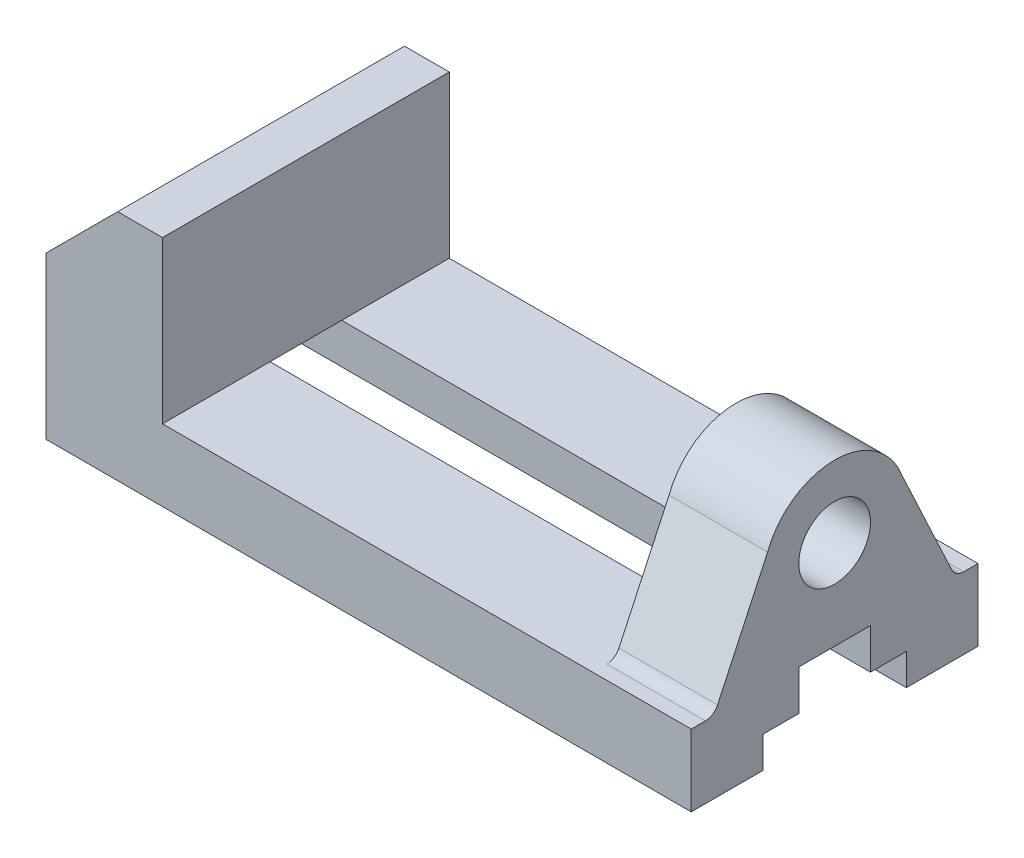
from build123d import *

# Parameters (mm, degrees)
SKETCH1_W                  = 144
SKETCH1_H                  = 64
BOSS_EXTRUDE1_DEPTH        = 16
SKETCH2_W                  = 26
SKETCH2_H                  = 64
BOSS_EXTRUDE2_DEPTH        = 36
CUT_EXTRUDE1_DEPTH         = 1
CUT_EXTRUDE1_DEPTH_BACK    = 65
SKETCH4_W                  = 22
SKETCH4_H                  = 64
BOSS_EXTRUDE3_DEPTH        = 36
CUT_EXTRUDE2_DEPTH         = 1
CUT_EXTRUDE2_DEPTH_BACK    = 145
SKETCH6_R                  = 8
CUT_EXTRUDE3_DEPTH         = 36
F_12_0MM_DOWEL_HOLE1_D     = 12
F_12_0MM_DOWEL_HOLE1_DEPTH = 10
F_12_0MM_DOWEL_HOLE1_TIP   = 3.605163714


with BuildPart() as part:
    # Sketch1 → Boss-Extrude1 (new body)
    with BuildSketch(Plane(origin=(0, 0, 0), x_dir=(1, 0, 0), z_dir=(0, 1, 0))):
        Rectangle(SKETCH1_W, SKETCH1_H)
    extrude(amount=BOSS_EXTRUDE1_DEPTH)

    # Sketch2 → Boss-Extrude2 (add)
    with BuildSketch(Plane(origin=(0, 16, 0), x_dir=(1, 0, 0), z_dir=(0, 1, 0))):
        with Locations((-59, 0)):
            Rectangle(SKETCH2_W, SKETCH2_H)
    extrude(amount=BOSS_EXTRUDE2_DEPTH)

    # Sketch3 → Cut-Extrude1 (cut, two sides)
    with BuildSketch(Plane.XY.offset(32)) as cut_extrude1_sk:
        Polygon((-72, 36), (-56, 52), (-72, 52), align=None)
    extrude(amount=CUT_EXTRUDE1_DEPTH, mode=Mode.SUBTRACT)
    extrude(cut_extrude1_sk.sketch, amount=-CUT_EXTRUDE1_DEPTH_BACK, mode=Mode.SUBTRACT)

    # Sketch4 → Boss-Extrude3 (add)
    with BuildSketch(Plane(origin=(0, 16, 0), x_dir=(1, 0, 0), z_dir=(0, 1, 0))):
        with Locations((61, 0)):
            Rectangle(SKETCH4_W, SKETCH4_H)
    extrude(amount=BOSS_EXTRUDE3_DEPTH)

    # Sketch5 → Cut-Extrude2 (cut, two sides)
    with BuildSketch(Plane(origin=(72, 0, 0), x_dir=(0, 0, -1), z_dir=(1, 0, 0))) as cut_extrude2_sk:
        Polygon((-16, 7), (-16, 0), (16, 0), (16, 7), (8, 7), (8, 16), (-8, 16), (-8, 7), align=None)
    extrude(amount=CUT_EXTRUDE2_DEPTH, mode=Mode.SUBTRACT)
    extrude(cut_extrude2_sk.sketch, amount=-CUT_EXTRUDE2_DEPTH_BACK, mode=Mode.SUBTRACT)

    # Sketch6 → Cut-Extrude3 (cut)
    with BuildSketch(Plane(origin=(72, 0, 0), x_dir=(0, 0, -1), z_dir=(1, 0, 0))):
        with BuildLine():
            Line((-32, 52), (-32, 16))
            Line((-32, 16), (-28.843717868, 16))
            ThreePointArc((-28.843717868, 16), (-27.231819043, 16.469825663), (-26.124794507, 17.732145215))
            Line((-26.124794507, 17.732145215), (-14.958449756, 41.678448811))
            ThreePointArc((-14.958449756, 41.678448811), (-9.086936164, 49.169190983), (8.8e-08, 52))
            Line((8.8e-08, 52), (-32, 52))
        make_face()
        with Locations((0, 36)):
            Circle(SKETCH6_R)
        with BuildLine():
            Line((32, 52), (8.8e-08, 52))
            ThreePointArc((8.8e-08, 52), (9.086936237, 49.169190933), (14.958449756, 41.678448811))
            Line((14.958449756, 41.678448811), (26.124794507, 17.732145215))
            ThreePointArc((26.124794507, 17.732145215), (27.231819043, 16.469825663), (28.843717868, 16))
            Line((28.843717868, 16), (32, 16))
            Line((32, 16), (32, 52))
        make_face()
    extrude(amount=-CUT_EXTRUDE3_DEPTH, mode=Mode.SUBTRACT)

    # Ø12.0mm Dowel Hole1
    with Locations(Plane(origin=(0, 0, 0), x_dir=(-1, 0, 0), z_dir=(0, -1, 0))):
        with Locations((34, -23.551834062), (-36, -23.551834062), (-36, 24.957913708), (34, 24.957913708)):
            Hole(F_12_0MM_DOWEL_HOLE1_D / 2, depth=F_12_0MM_DOWEL_HOLE1_DEPTH)
            with Locations((0, 0, -(F_12_0MM_DOWEL_HOLE1_DEPTH + F_12_0MM_DOWEL_HOLE1_TIP / 2))):  # 118° drill point
                Cone(0, F_12_0MM_DOWEL_HOLE1_D / 2, F_12_0MM_DOWEL_HOLE1_TIP, mode=Mode.SUBTRACT)


solid = part.part
